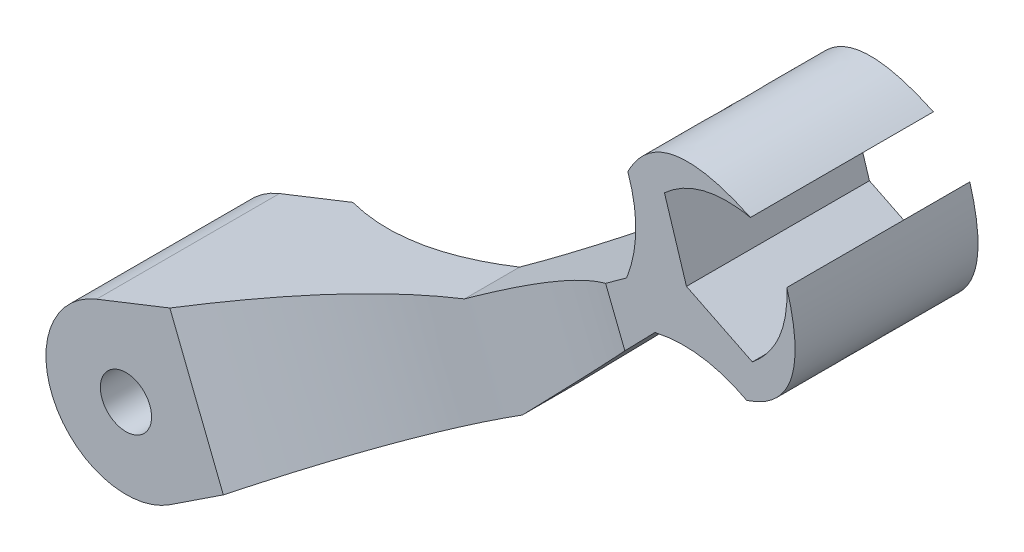
from build123d import *

# Parameters (mm, degrees)
BOSS_EXTRUDE1_DEPTH             = 20.32
BOSS_EXTRUDE1_DEPTH_BACK        = 20.32
SKETCH1_R                       = 10.16
CUT_EXTRUDE2_DEPTH              = 85.09
CUT_EXTRUDE2_DEPTH_BACK         = 85.09
BOSS_EXTRUDE2_REACH             = 187.218
SKETCH4_R                       = 10.16
SKETCH4_R_2                     = 5.690130056
BOSS_EXTRUDE2_DIRECTION_2_REACH = 187.218


with BuildPart() as part:
    # Sketch1 → Boss-Extrude1 (new, two sides: drawn at the far end of the back side and taken through both)
    with BuildSketch(Plane.XY.offset(-BOSS_EXTRUDE1_DEPTH_BACK)):
        with BuildLine():
            Line((-6.540792976, 16.533191684), (60.990787353, 43.249756441))
            Line((60.990787353, 43.249756441), (111.219656073, 79.494763154))
            add(Edge.make_bspline(
                [(111.219656073, 79.494763154), (115.143809103, 89.538582986), (111.485189552, 100.079798905)],
                knots=[0, 0, 0, 1, 1, 1], degree=2))
            add(Edge.make_bspline(
                [(111.485189552, 100.079798905), (118.666753914, 114.310676005), (138.716144692, 104.878983682)],
                knots=[0, 0, 0, 1, 1, 1], degree=2))
            add(Edge.make_bspline(
                [(119.614328761, 100.079798905), (127.464188518, 107.13262314), (138.716144692, 104.878983682)],
                knots=[0, 0, 0, 1, 1, 1], degree=2))
            Line((119.614328761, 100.079798905), (124.506668386, 84.517246437))
            Line((124.506668386, 84.517246437), (139.137891823, 77.302308665))
            add(Edge.make_bspline(
                [(139.137891823, 77.302308665), (147.308308442, 83.981149896), (146.802069804, 95.445404385)],
                knots=[0, 0, 0, 1, 1, 1], degree=2))
            add(Edge.make_bspline(
                [(137.894611709, 69.268806388), (153.056423627, 74.189394673), (146.802069804, 95.445404385)],
                knots=[0, 0, 0, 1, 1, 1], degree=2))
            add(Edge.make_bspline(
                [(117.511141846, 72.154696419), (128.036963673, 74.496569321), (137.894611709, 69.268806388)],
                knots=[0, 0, 0, 1, 1, 1], degree=2))
            Line((117.511141846, 72.154696419), (74.032842511, 27.522572281))
            Line((74.032842511, 27.522572281), (9.788223937, -14.843148998))
            ThreePointArc((9.788223937, -14.843148998), (-15.771973263, -8.208121551), (-6.540792976, 16.533191684))
        make_face()
        Circle(SKETCH1_R, mode=Mode.SUBTRACT)
    extrude(amount=BOSS_EXTRUDE1_DEPTH + BOSS_EXTRUDE1_DEPTH_BACK)

    # Sketch3 → Cut-Extrude2 (cut, two sides: drawn at the far end of the back side and taken through both)
    with BuildSketch(Plane(origin=(-6.540792976, 16.533191684, 0), x_dir=(0.9298757977302595, 0.3678736206844866, 0), z_dir=(-0.3678736206844866, 0.9298757977302596, 0)).offset(-CUT_EXTRUDE2_DEPTH_BACK)):
        with BuildLine():
            Line((17.521009343, 20.32), (69.311227208, 80.494269298))
            Line((69.311227208, 80.494269298), (134.577572969, 24.523321464))
            add(Edge.make_bspline(
                [(17.521009343, 20.32), (76.642520542, -10.04244022), (134.577572969, 24.523321464)],
                knots=[0, 0, 0, 1, 1, 1], degree=2))
        make_face()
        with BuildLine():
            Line((17.521009343, -20.32), (69.311227208, -80.494269298))
            Line((69.311227208, -80.494269298), (134.577572969, -24.523321464))
            add(Edge.make_bspline(
                [(17.521009343, -20.32), (76.642520542, 10.04244022), (134.577572969, -24.523321464)],
                knots=[0, 0, 0, 1, 1, 1], degree=2))
        make_face()
    extrude(amount=CUT_EXTRUDE2_DEPTH + CUT_EXTRUDE2_DEPTH_BACK, mode=Mode.SUBTRACT)

    # Boss-Extrude2: up to this face of the body (flat: up to its plane)
    boss_extrude2_end = Plane(part.part.faces().sort_by_distance((-15.269069271, -7.946397985, 20.32))[0])
    # Sketch4 → Boss-Extrude2 (add, up to the picked face)
    with BuildSketch(Plane.XY, mode=Mode.PRIVATE) as boss_extrude2_sk1:
        Circle(SKETCH4_R)
        Circle(SKETCH4_R_2, mode=Mode.SUBTRACT)
    boss_extrude2_tool1 = split(extrude(boss_extrude2_sk1.sketch, amount=BOSS_EXTRUDE2_REACH, mode=Mode.PRIVATE), bisect_by=boss_extrude2_end, keep=Keep.BOTH, mode=Mode.PRIVATE)
    add(boss_extrude2_tool1.solids().sort_by(Axis((-9.872632, 0, 0), (0, 0, 1)))[0])

    # Boss-Extrude2 direction 2: up to this face of the body (flat: up to its plane)
    boss_extrude2_direction_2_end = Plane(part.part.faces().sort_by_distance((-15.269069271, -7.946397985, -20.32))[0])
    # Sketch4 → Boss-Extrude2 direction 2 (add, up to the picked face)
    with BuildSketch(Plane.XY, mode=Mode.PRIVATE) as boss_extrude2_direction_2_sk1:
        Circle(SKETCH4_R)
        Circle(SKETCH4_R_2, mode=Mode.SUBTRACT)
    boss_extrude2_direction_2_tool1 = split(extrude(boss_extrude2_direction_2_sk1.sketch, amount=-BOSS_EXTRUDE2_DIRECTION_2_REACH, mode=Mode.PRIVATE), bisect_by=boss_extrude2_direction_2_end, keep=Keep.BOTH, mode=Mode.PRIVATE)
    add(boss_extrude2_direction_2_tool1.solids().sort_by(Axis((-9.872632, 0, 0), (0, 0, -1)))[0])


solid = part.part
